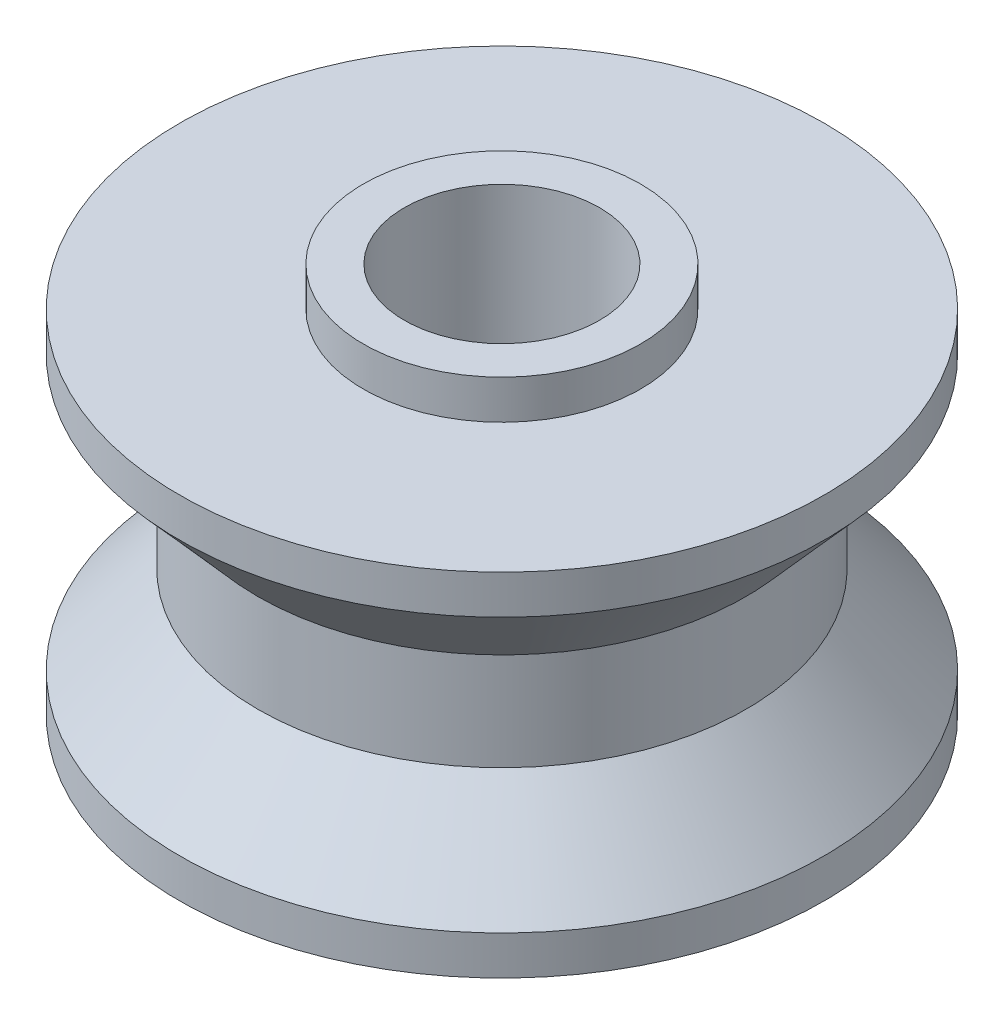
from build123d import *


with BuildPart() as part:
    # 草图1 → 旋转1 (revolve)
    with BuildSketch(Plane.XY):
        Polygon((2.5, 5.5), (3.55, 5.5), (3.55, 4.5), (8.25, 4.5), (8.25, 3.5), (6.25, 1.25), (6.25, -1.25), (8.25, -3.5), (8.25, -4.5), (3.55, -4.5), (3.55, -5.5), (2.5, -5.5), align=None)
    revolve(axis=Axis((0, 0, 0), (0, 1, 0)))


solid = part.part
